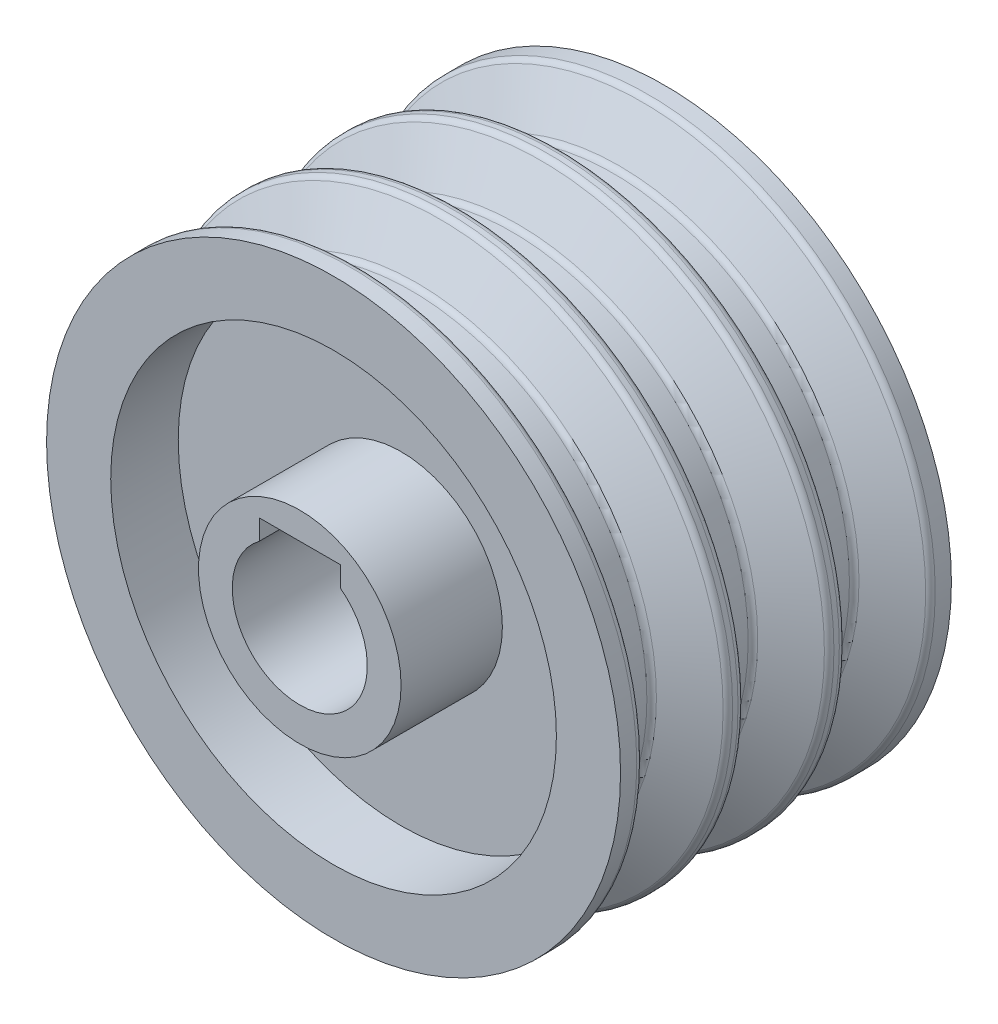
from build123d import *

# Parameters (mm, degrees)
ESBO_O1_R                = 42.5
ESBO_O1_R_2              = 33
RESSALTO_EXTRUS_O1_DEPTH = 24.5
ESBO_O1_3_R              = 15
RESSALTO_EXTRUS_O2_DEPTH = 29.5
ESBO_O1_4_R              = 33
ESBO_O1_4_R_2            = 15
RESSALTO_EXTRUS_O3_DEPTH = 14.5
FILETE1_R                = 1


with BuildPart() as part:
    # Esboço1 → Ressalto-extrusão1 (new, symmetric)
    with BuildSketch(Plane.XY):
        Circle(ESBO_O1_R)
        Circle(ESBO_O1_R_2, mode=Mode.SUBTRACT)
    extrude(amount=RESSALTO_EXTRUS_O1_DEPTH, both=True)



with BuildPart() as body_2:
    # Esboço1<3> → Ressalto-extrusão2 (new, symmetric)
    with BuildSketch(Plane.XY):
        Circle(ESBO_O1_3_R)
        with BuildLine():
            Line((-6, 11), (6, 11))
            Line((6, 11), (6, 8))
            ThreePointArc((6, 8), (0, -10), (-6, 8))
            Line((-6, 8), (-6, 11))
        make_face(mode=Mode.SUBTRACT)
    extrude(amount=RESSALTO_EXTRUS_O2_DEPTH, both=True)


with BuildPart() as part_1:
    add(part.part)

    add(body_2.part)  # Ressalto-extrusão3 merges body 2
    # Esboço1<4> → Ressalto-extrusão3 (add, symmetric)
    with BuildSketch(Plane.XY):
        Circle(ESBO_O1_4_R)
        Circle(ESBO_O1_4_R_2, mode=Mode.SUBTRACT)
    extrude(amount=RESSALTO_EXTRUS_O3_DEPTH, both=True)

    # Esboço2 → Corte-Revolução1 (revolve, cut)
    with BuildSketch(Plane(origin=(0, 0, 0), x_dir=(0, 0, -1), z_dir=(1, 0, 0))):
        Polygon((-8.5, 42.5), (-21.5, 42.5), (-17.5, 35), (-12.5, 35), align=None)
        Polygon((6.5, 42.5), (-6.5, 42.5), (-2.5, 35), (2.5, 35), align=None)
        Polygon((21.5, 42.5), (8.5, 42.5), (12.5, 35), (17.5, 35), align=None)
    revolve(axis=Axis((0, 0, 1000), (0, 0, -1)), mode=Mode.SUBTRACT)

    # Filete1
    filete1_edges = [part_1.edges().sort_by_distance(p)[0] for p in [
        (30.0520382, 30.0520382, -21.5),
        (0, -35, -17.5),
        (0, -35, -12.5),
        (-30.0520382, -30.0520382, -8.5),
        (30.0520382, 30.0520382, -6.5),
        (0, -35, -2.5),
        (0, -35, 2.5),
        (-30.0520382, -30.0520382, 6.5),
        (30.0520382, 30.0520382, 8.5),
        (-30.0520382, -30.0520382, 21.5),
        (0, -35, 12.5),
        (0, -35, 17.5),
    ]]
    fillet(filete1_edges, radius=FILETE1_R)


solid = part_1.part
